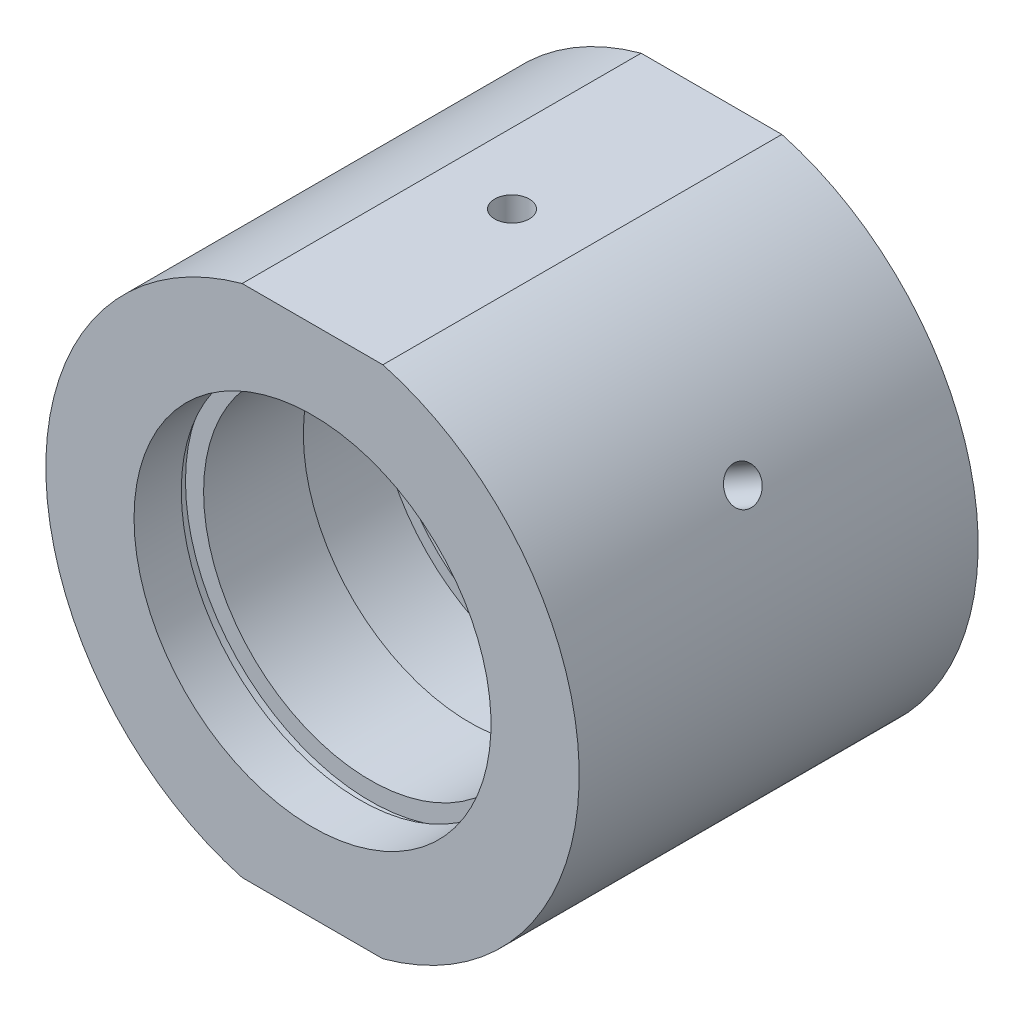
from build123d import *

# Parameters (mm, degrees)
SKETCH_2_W                       = 64.02174429
SKETCH_2_H                       = 9.248919907
CUT_EXTRUDE_1_DEPTH              = 49
HOLE_WIZARD_M4_2_D               = 3.3
HOLE_WIZARD_M4_2_DEPTH           = 5.5
HOLE_WIZARD_M4_2_TIP             = 0.991420021
HOLE_WIZARD_M6_2_D               = 5
HOLE_WIZARD_M6_2_DEPTH           = 5.5
HOLE_WIZARD_M6_2_TIP             = 1.502151548
HOLE_WIZARD_M4_3_D               = 3.3
HOLE_WIZARD_M4_3_DEPTH           = 10.1
HOLE_WIZARD_M4_3_TIP             = 0.991420021
HOLE_WIZARD_M4_3_ON_FACE_2_D     = 3.3
HOLE_WIZARD_M4_3_ON_FACE_2_DEPTH = 10.1
HOLE_WIZARD_M4_3_ON_FACE_2_TIP   = 0.991420021


with BuildPart() as part:
    # 草图1 → 旋转1 (revolve)
    with BuildSketch(Plane(origin=(0, 0, 0), x_dir=(1, 0, 0), z_dir=(0, 1, 0)), mode=Mode.PRIVATE) as revolve_1_sk:
        Polygon((25.4, 19), (25.4, -19), (17, -19), (17, -14.5), (17.6, -14.5), (17.6, -13.5), (15.875, -13.5), (15.875, -4), (16.975, -4), (16.975, 4), (15.875, 4), (15.875, 13.5), (17.6, 13.5), (17.6, 14.5), (17, 14.5), (17, 19), align=None)
    revolve(revolve_1_sk.sketch.rotate(Axis((0, 0, -31.9390681), (0, 0, 1)), 180), axis=Axis((0, 0, -31.9390681), (0, 0, 1)))  # turned: the seam where the file's is

    # 草图2 → 切除-拉伸1 (cut)
    with BuildSketch(Plane.XY.offset(19)):
        with Locations((-1.141100508, 29.124459954)):
            Rectangle(SKETCH_2_W, SKETCH_2_H)
        with Locations((-1.141100508, -29.124459954)):
            Rectangle(SKETCH_2_W, SKETCH_2_H)
    extrude(amount=-CUT_EXTRUDE_1_DEPTH, mode=Mode.SUBTRACT)

    # M4 螺纹孔2
    with Locations(Plane(origin=(0, 24.5, 0), x_dir=(1, 0, 0), z_dir=(0, 1, 0))):
        with Locations((0, 0)):
            Hole(HOLE_WIZARD_M4_2_D / 2, depth=HOLE_WIZARD_M4_2_DEPTH)
            with Locations((0, 0, -(HOLE_WIZARD_M4_2_DEPTH + HOLE_WIZARD_M4_2_TIP / 2))):  # 118° drill point
                Cone(0, HOLE_WIZARD_M4_2_D / 2, HOLE_WIZARD_M4_2_TIP, mode=Mode.SUBTRACT)

    # M6 螺纹孔2
    with Locations(Plane(origin=(0, -24.5, 0), x_dir=(-1, 0, 0), z_dir=(0, -1, 0))):
        with Locations((0, 0)):
            Hole(HOLE_WIZARD_M6_2_D / 2, depth=HOLE_WIZARD_M6_2_DEPTH)
            with Locations((0, 0, -(HOLE_WIZARD_M6_2_DEPTH + HOLE_WIZARD_M6_2_TIP / 2))):  # 118° drill point
                Cone(0, HOLE_WIZARD_M6_2_D / 2, HOLE_WIZARD_M6_2_TIP, mode=Mode.SUBTRACT)

    # M4 螺纹孔3
    with Locations(Plane(origin=(21.997045256, 12.7, 0), x_dir=(-0.5, 0.866025404, 0), z_dir=(0.866025404, 0.5, 0))):
        with Locations((0, 0)):
            Hole(HOLE_WIZARD_M4_3_D / 2, depth=HOLE_WIZARD_M4_3_DEPTH)
            with Locations((0, 0, -(HOLE_WIZARD_M4_3_DEPTH + HOLE_WIZARD_M4_3_TIP / 2))):  # 118° drill point
                Cone(0, HOLE_WIZARD_M4_3_D / 2, HOLE_WIZARD_M4_3_TIP, mode=Mode.SUBTRACT)

    # M4 螺纹孔3 on face 2
    with Locations(Plane(origin=(-21.997045256, 12.7, 0), x_dir=(-0.500000175, -0.866025303, 0), z_dir=(-0.866025303, 0.500000175, 0))):
        with Locations((0, 0)):
            Hole(HOLE_WIZARD_M4_3_ON_FACE_2_D / 2, depth=HOLE_WIZARD_M4_3_ON_FACE_2_DEPTH)
            with Locations((0, 0, -(HOLE_WIZARD_M4_3_ON_FACE_2_DEPTH + HOLE_WIZARD_M4_3_ON_FACE_2_TIP / 2))):  # 118° drill point
                Cone(0, HOLE_WIZARD_M4_3_ON_FACE_2_D / 2, HOLE_WIZARD_M4_3_ON_FACE_2_TIP, mode=Mode.SUBTRACT)


solid = part.part
